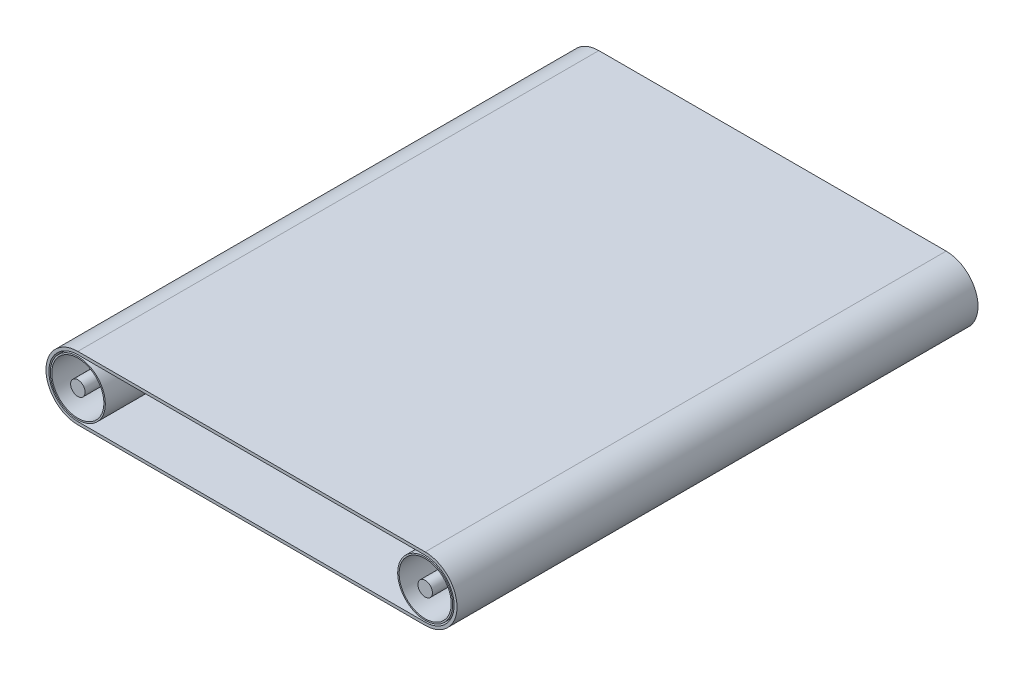
from build123d import *

# Parameters (mm, degrees)
BOSS_EXTRU_1_DEPTH   = 180
ESQUISSE2_R          = 2.5
BOSS_EXTRU_2_DEPTH   = 180
BOSS_EXTRU_2_2_DEPTH = 180
ESQUISSE3_R          = 9.5
ESQUISSE3_R_2        = 9
BOSS_EXTRU_3_DEPTH   = 180
BOSS_EXTRU_3_2_DEPTH = 180


with BuildPart() as part:
    # Esquisse1 → Boss.-Extru.1 (new body)
    with BuildSketch(Plane.XY):
        with BuildLine():
            Line((0, 21), (120, 21))
            ThreePointArc((120, 21), (131, 10), (120, -1))
            Line((120, -1), (0, -1))
            ThreePointArc((0, -1), (-11, 10), (0, 21))
        make_face()
        with BuildLine():
            Line((0, 0), (120, 0))
            ThreePointArc((120, 0), (130, 10), (120, 20))
            Line((120, 20), (0, 20))
            ThreePointArc((0, 20), (-10, 10), (0, 0))
        make_face(mode=Mode.SUBTRACT)
    extrude(amount=BOSS_EXTRU_1_DEPTH)


with BuildPart() as body_2:
    # Esquisse2 → Boss.-Extru.2 (new body)
    with BuildSketch(Plane.XY.offset(180)):
        with Locations((0, 10)):
            Circle(ESQUISSE2_R)
    extrude(amount=-BOSS_EXTRU_2_DEPTH)


with BuildPart() as body_3:
    # Esquisse2 → Boss.-Extru.2 2 (new body)
    with BuildSketch(Plane.XY.offset(180)):
        with Locations((120, 10)):
            Circle(ESQUISSE2_R)
    extrude(amount=-BOSS_EXTRU_2_2_DEPTH)


with BuildPart() as body_4:
    # Esquisse3 → Boss.-Extru.3 (new body)
    with BuildSketch(Plane.XY.offset(180)):
        with Locations((0, 10)):
            Circle(ESQUISSE3_R)
        with Locations((0, 10)):
            Circle(ESQUISSE3_R_2, mode=Mode.SUBTRACT)
    extrude(amount=-BOSS_EXTRU_3_DEPTH)


with BuildPart() as body_5:
    # Esquisse3 → Boss.-Extru.3 2 (new body)
    with BuildSketch(Plane.XY.offset(180)):
        with Locations((120, 10)):
            Circle(ESQUISSE3_R)
        with Locations((120, 10)):
            Circle(ESQUISSE3_R_2, mode=Mode.SUBTRACT)
    extrude(amount=-BOSS_EXTRU_3_2_DEPTH)


solid = Compound([part.part, body_2.part, body_3.part, body_4.part, body_5.part])
